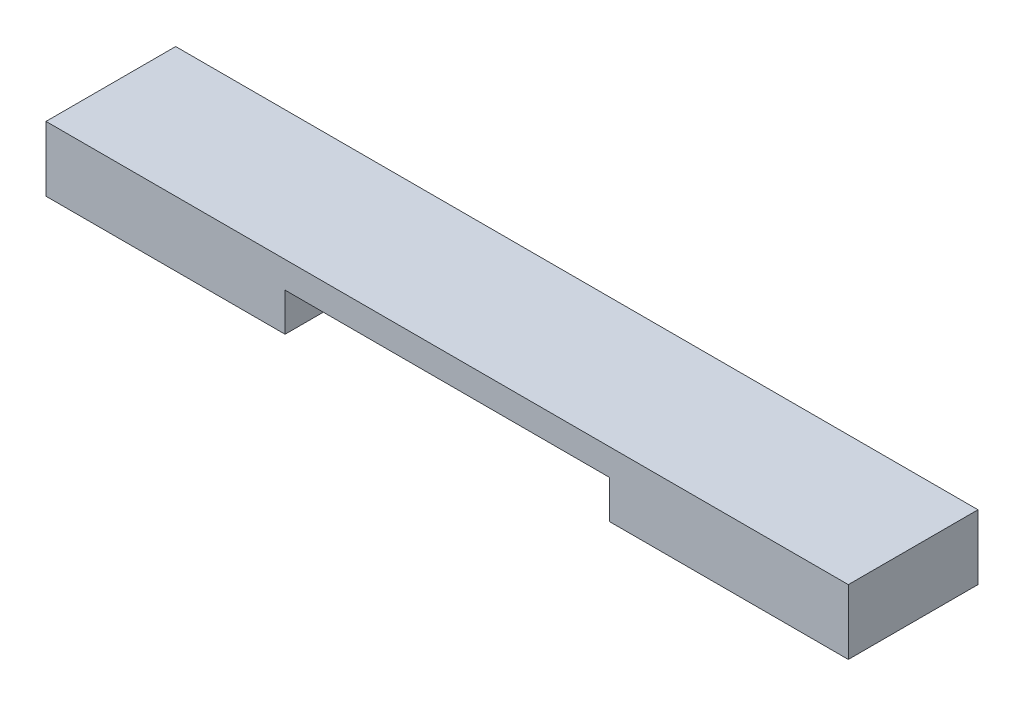
from build123d import *

# Parameters (mm, degrees)
BOSS_EXTRUDE1_DEPTH = 8


with BuildPart() as part:
    # Sketch1 → Boss-Extrude1 (new body)
    with BuildSketch(Plane.XY):
        Polygon((-24.75, -2), (-10, -2), (-10, 0.36), (10, 0.36), (10, -2), (24.75, -2), (24.75, 2), (-24.75, 2), align=None)
    extrude(amount=BOSS_EXTRUDE1_DEPTH)


solid = part.part
